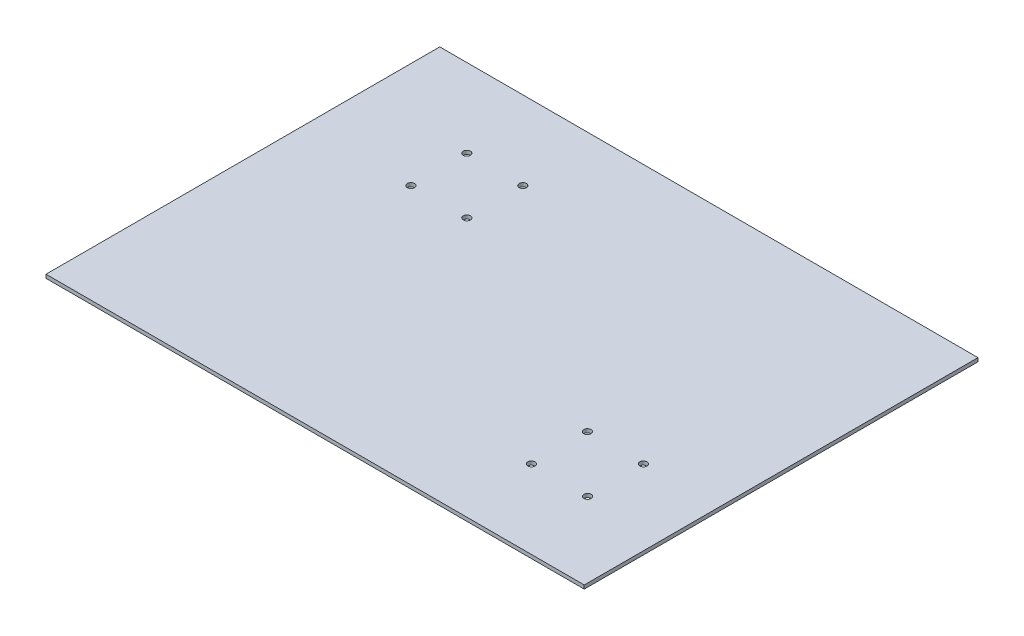
from build123d import *

# Parameters (mm, degrees)
SKETCH1_W           = 218
SKETCH1_H           = 2
BOSS_EXTRUDE1_DEPTH = 298
SKETCH2_R           = 2
CUT_EXTRUDE1_DEPTH  = 10


with BuildPart() as part:
    # Sketch1 → Boss-Extrude1 (new body)
    with BuildSketch(Plane(origin=(0, 0, 0), x_dir=(0, 0, -1), z_dir=(1, 0, 0))):
        with Locations((82.3216851, 1)):
            Rectangle(SKETCH1_W, SKETCH1_H)
    extrude(amount=BOSS_EXTRUDE1_DEPTH)

    # Sketch2 → Cut-Extrude1 (cut)
    with BuildSketch(Plane(origin=(0, 2, 0), x_dir=(1, 0, 0), z_dir=(0, 1, 0))):
        with Locations((89.5, 116.8216851)):
            Circle(SKETCH2_R)
        with Locations((58.5, 116.8216851)):
            Circle(SKETCH2_R)
        with Locations((89.5, 147.8216851)):
            Circle(SKETCH2_R)
        with Locations((58.5, 147.8216851)):
            Circle(SKETCH2_R)
        with Locations((256.33130124, 47.719426297)):
            Circle(SKETCH2_R)
        with Locations((256.457517214, 16.719426297)):
            Circle(SKETCH2_R)
        with Locations((225.33130124, 16.719426297)):
            Circle(SKETCH2_R)
        with Locations((225.33130124, 47.719426297)):
            Circle(SKETCH2_R)
    extrude(amount=-CUT_EXTRUDE1_DEPTH, mode=Mode.SUBTRACT)


solid = part.part
